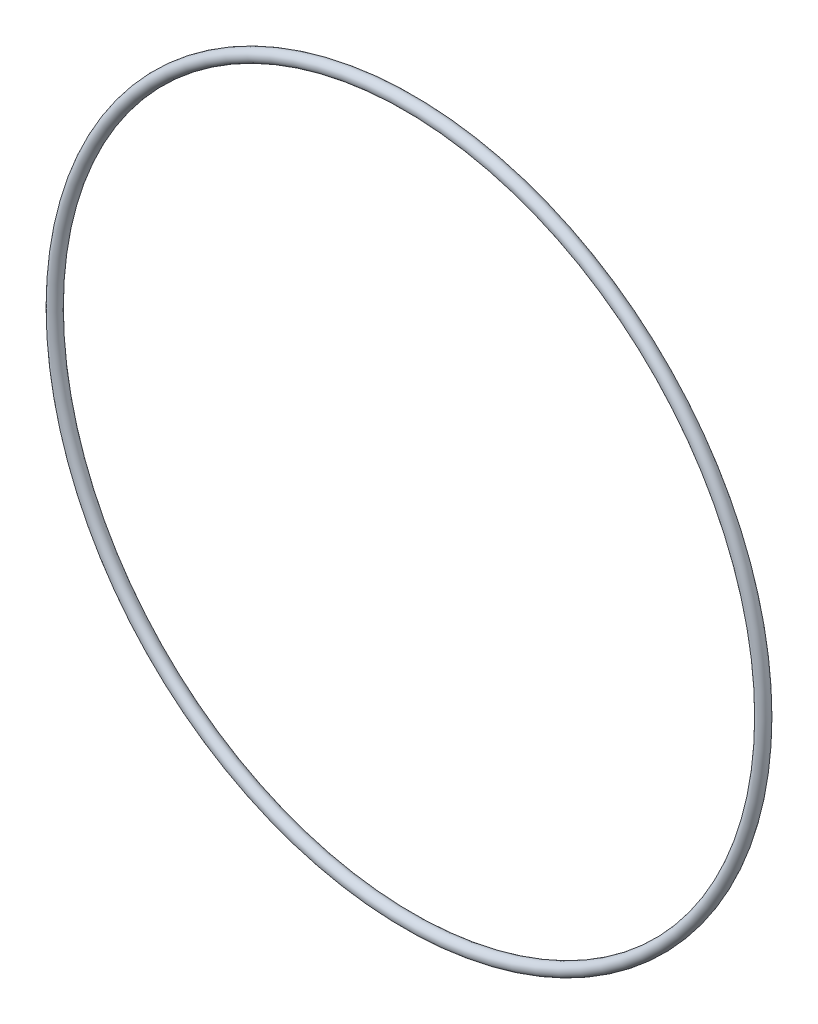
from build123d import *

# Parameters (mm, degrees)
SKETCH1_R = 0.889


with BuildPart() as part:
    # Sketch1 → Revolve1 (revolve)
    with BuildSketch(Plane(origin=(0, 0, 0), x_dir=(0, -1, 0), z_dir=(1, 0, 0))):
        with Locations((51.5493, 0)):
            Circle(SKETCH1_R)
    revolve(axis=Axis((0, 0, 0.889), (0, 0, -1)))


solid = part.part
